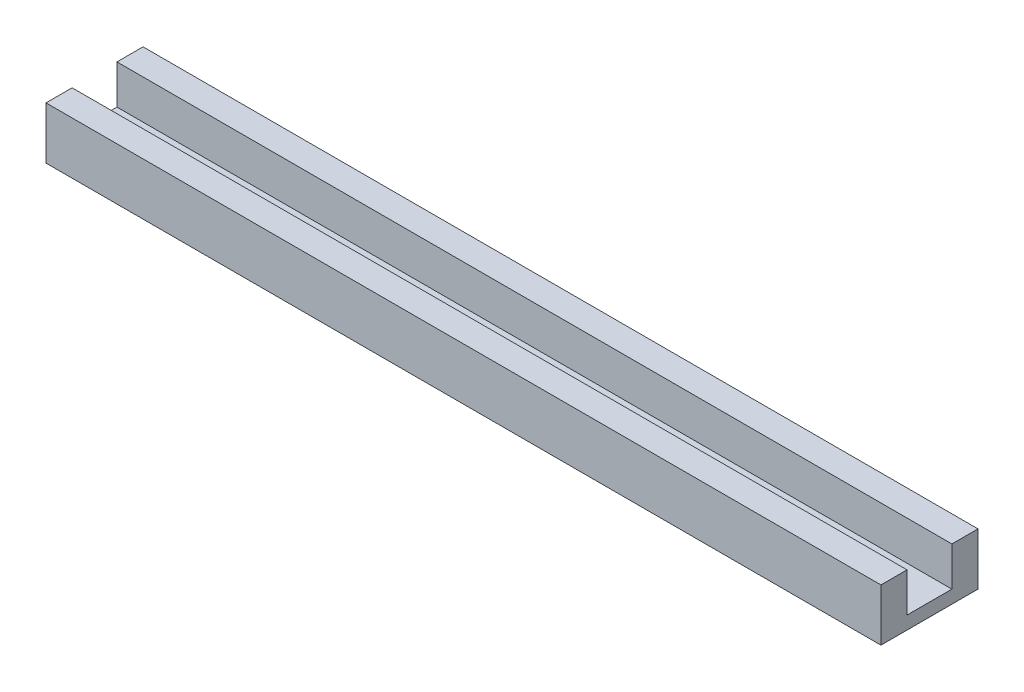
from build123d import *

# Parameters (mm, degrees)
SKETCH2_W           = 203.2
SKETCH2_H           = 23.622
BOSS_EXTRUDE2_DEPTH = 3.175
SKETCH3_W           = 203.2
SKETCH3_H           = 6.35
BOSS_EXTRUDE3_DEPTH = 9.525


with BuildPart() as part:
    # Sketch2 → Boss-Extrude2 (new body)
    with BuildSketch(Plane(origin=(0, 0, 0), x_dir=(1, 0, 0), z_dir=(0, 1, 0))):
        with Locations((85.86534864, 0.852340206)):
            Rectangle(SKETCH2_W, SKETCH2_H)
    extrude(amount=BOSS_EXTRUDE2_DEPTH)

    # Sketch3 → Boss-Extrude3 (add)
    with BuildSketch(Plane(origin=(0, 3.175, 0), x_dir=(1, 0, 0), z_dir=(0, 1, 0))):
        with Locations((85.86534864, 9.488340206)):
            Rectangle(SKETCH3_W, SKETCH3_H)
        with Locations((85.86534864, -7.783659794)):
            Rectangle(SKETCH3_W, SKETCH3_H)
    extrude(amount=BOSS_EXTRUDE3_DEPTH)


solid = part.part
